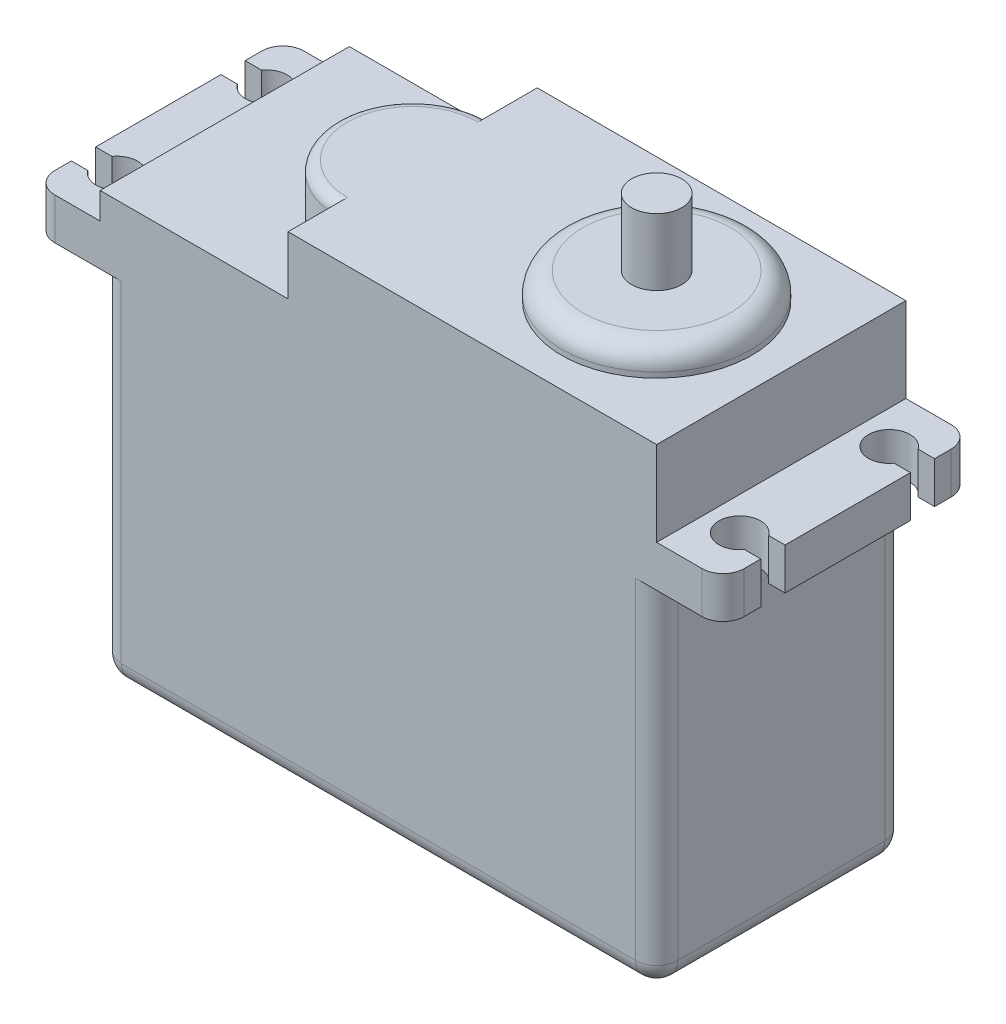
from build123d import *

# Parameters (mm, degrees)
EXTRUDE1_DEPTH     = 30
FILLET1_R          = 2.54
CUT_EXTRUDE1_REACH = 71.778
SKETCH2_R          = 2.5
CUT_EXTRUDE2_REACH = 71.778
SKETCH3_W          = 3.948997199
SKETCH3_H          = 2.915862496
SKETCH3_W_2        = 5.260004778
SKETCH3_W_3        = 4.51085759
EXTRUDE2_DEPTH     = 7.004916842
SKETCH5_R          = 11.43
EXTRUDE3_DEPTH     = 3.175
FILLET2_R          = 2.54
FILLET3_R          = 1.27
SKETCH6_R          = 3.013004542
EXTRUDE4_DEPTH     = 8.025


with BuildPart() as part:
    # Sketch1 → Extrude1 (new body)
    with BuildSketch(Plane.XY):
        Polygon((-33.5, 17.102458421), (-41.5, 17.102458421), (-41.5, 22.102458421), (-33.5, 22.102458421), (-33.5, 25.297541579), (-10.877689124, 25.297541579), (-10.877689124, 32.302458421), (33.5, 32.302458421), (33.5, 22.102458421), (41.5, 22.102458421), (41.5, 17.102458421), (33.5, 17.102458421), (33.5, -25.297541579), (-33.5, -25.297541579), align=None)
    extrude(amount=EXTRUDE1_DEPTH)

    # Fillet1
    fillet1_edges = [part.edges().sort_by_distance(p)[0] for p in [
        (33.5, -4.097541579, 30),
        (-41.5, 19.602458421, 0),
        (41.5, 19.602458421, 30),
        (41.5, 19.602458421, 0),
        (33.5, -4.097541579, 0),
        (0, -25.297541579, 0),
        (-33.5, -4.097541579, 0),
        (33.5, -25.297541579, 15),
        (-33.5, -25.297541579, 15),
        (-33.5, -4.097541579, 30),
        (-41.5, 19.602458421, 30),
        (0, -25.297541579, 30),
    ]]
    fillet(fillet1_edges, radius=FILLET1_R)

    # Sketch2 → Cut-Extrude1 (cut, up to next)
    with BuildSketch(Plane(origin=(0, 22.102458421, 0), x_dir=(1, 0, 0), z_dir=(0, 1, 0)), mode=Mode.PRIVATE) as cut_extrude1_sk1:
        with Locations(Location((-37.5, -6, 0), (0, 0, 270))):
            Circle(SKETCH2_R)
    cut_extrude1_tool1 = extrude(cut_extrude1_sk1.sketch, amount=-CUT_EXTRUDE1_REACH, mode=Mode.PRIVATE) & part.part
    # Sketch2 → Cut-Extrude1 (cut, up to next)
    with BuildSketch(Plane(origin=(0, 22.102458421, 0), x_dir=(1, 0, 0), z_dir=(0, 1, 0)), mode=Mode.PRIVATE) as cut_extrude1_sk2:
        with Locations(Location((-37.5, -24, 0), (0, 0, 270))):
            Circle(SKETCH2_R)
    cut_extrude1_tool2 = extrude(cut_extrude1_sk2.sketch, amount=-CUT_EXTRUDE1_REACH, mode=Mode.PRIVATE) & part.part
    # Sketch2 → Cut-Extrude1 (cut, up to next)
    with BuildSketch(Plane(origin=(0, 22.102458421, 0), x_dir=(1, 0, 0), z_dir=(0, 1, 0)), mode=Mode.PRIVATE) as cut_extrude1_sk3:
        with Locations(Location((37.5, -6, 0), (0, 0, 270))):
            Circle(SKETCH2_R)
    cut_extrude1_tool3 = extrude(cut_extrude1_sk3.sketch, amount=-CUT_EXTRUDE1_REACH, mode=Mode.PRIVATE) & part.part
    # Sketch2 → Cut-Extrude1 (cut, up to next)
    with BuildSketch(Plane(origin=(0, 22.102458421, 0), x_dir=(1, 0, 0), z_dir=(0, 1, 0)), mode=Mode.PRIVATE) as cut_extrude1_sk4:
        with Locations(Location((37.5, -24, 0), (0, 0, 270))):
            Circle(SKETCH2_R)
    cut_extrude1_tool4 = extrude(cut_extrude1_sk4.sketch, amount=-CUT_EXTRUDE1_REACH, mode=Mode.PRIVATE) & part.part
    add(cut_extrude1_tool1.solids().sort_by_distance((-37.5, 22.102458, 6))[0], mode=Mode.SUBTRACT)
    add(cut_extrude1_tool2.solids().sort_by_distance((-37.5, 22.102458, 24))[0], mode=Mode.SUBTRACT)
    add(cut_extrude1_tool3.solids().sort_by_distance((37.5, 22.102458, 6))[0], mode=Mode.SUBTRACT)
    add(cut_extrude1_tool4.solids().sort_by_distance((37.5, 22.102458, 24))[0], mode=Mode.SUBTRACT)

    # Sketch3 → Cut-Extrude2 (cut, up to next)
    with BuildSketch(Plane(origin=(0, 22.102458421, 0), x_dir=(1, 0, 0), z_dir=(0, 1, 0)), mode=Mode.PRIVATE) as cut_extrude2_sk1:
        with Locations((-39.525501401, -6)):
            Rectangle(SKETCH3_W, SKETCH3_H)
    cut_extrude2_tool1 = extrude(cut_extrude2_sk1.sketch, amount=-CUT_EXTRUDE2_REACH, mode=Mode.PRIVATE) & part.part
    # Sketch3 → Cut-Extrude2 (cut, up to next)
    with BuildSketch(Plane(origin=(0, 22.102458421, 0), x_dir=(1, 0, 0), z_dir=(0, 1, 0)), mode=Mode.PRIVATE) as cut_extrude2_sk2:
        with Locations((-39.525501401, -24)):
            Rectangle(SKETCH3_W, SKETCH3_H)
    cut_extrude2_tool2 = extrude(cut_extrude2_sk2.sketch, amount=-CUT_EXTRUDE2_REACH, mode=Mode.PRIVATE) & part.part
    # Sketch3 → Cut-Extrude2 (cut, up to next)
    with BuildSketch(Plane(origin=(0, 22.102458421, 0), x_dir=(1, 0, 0), z_dir=(0, 1, 0)), mode=Mode.PRIVATE) as cut_extrude2_sk3:
        with Locations((38.869997611, -6)):
            Rectangle(SKETCH3_W_2, SKETCH3_H)
    cut_extrude2_tool3 = extrude(cut_extrude2_sk3.sketch, amount=-CUT_EXTRUDE2_REACH, mode=Mode.PRIVATE) & part.part
    # Sketch3 → Cut-Extrude2 (cut, up to next)
    with BuildSketch(Plane(origin=(0, 22.102458421, 0), x_dir=(1, 0, 0), z_dir=(0, 1, 0)), mode=Mode.PRIVATE) as cut_extrude2_sk4:
        with Locations((39.244571205, -24)):
            Rectangle(SKETCH3_W_3, SKETCH3_H)
    cut_extrude2_tool4 = extrude(cut_extrude2_sk4.sketch, amount=-CUT_EXTRUDE2_REACH, mode=Mode.PRIVATE) & part.part
    add(cut_extrude2_tool1.solids().sort_by_distance((-39.525501, 22.102458, 6))[0], mode=Mode.SUBTRACT)
    add(cut_extrude2_tool2.solids().sort_by_distance((-39.525501, 22.102458, 24))[0], mode=Mode.SUBTRACT)
    add(cut_extrude2_tool3.solids().sort_by_distance((38.869998, 22.102458, 6))[0], mode=Mode.SUBTRACT)
    add(cut_extrude2_tool4.solids().sort_by_distance((39.244571, 22.102458, 24))[0], mode=Mode.SUBTRACT)

    # Sketch4 → Extrude2 (add)
    with BuildSketch(Plane(origin=(0, 25.297541579, 0), x_dir=(1, 0, 0), z_dir=(0, 1, 0))):
        with BuildLine():
            Line((-10.877689124, -5.869768646), (-10.877689124, -24.130231354))
            ThreePointArc((-10.877689124, -24.130231354), (-20.007920479, -15), (-10.877689124, -5.869768646))
        make_face()
    extrude(amount=EXTRUDE2_DEPTH)

    # Sketch5 → Extrude3 (add)
    with BuildSketch(Plane(origin=(0, 32.302458421, 0), x_dir=(1, 0, 0), z_dir=(0, 1, 0))):
        with Locations(Location((18.5, -15, 0), (0, 0, 90))):
            Circle(SKETCH5_R)
    extrude(amount=EXTRUDE3_DEPTH)

    # Fillet2
    fillet2_edges = [part.edges().sort_by_distance(p)[0] for p in [
        (18.5, 35.477458421, 26.43),
    ]]
    fillet(fillet2_edges, radius=FILLET2_R)

    # Fillet3
    fillet3_edges = [part.edges().sort_by_distance(p)[0] for p in [
        (-20.007920479, 32.302458421, 15),
    ]]
    fillet(fillet3_edges, radius=FILLET3_R)

    # Sketch6 → Extrude4 (add)
    with BuildSketch(Plane(origin=(0, 35.477458421, 0), x_dir=(1, 0, 0), z_dir=(0, 1, 0))):
        with Locations(Location((18.5, -15, 0), (0, 0, 180))):
            Circle(SKETCH6_R)
    extrude(amount=EXTRUDE4_DEPTH)


solid = part.part
